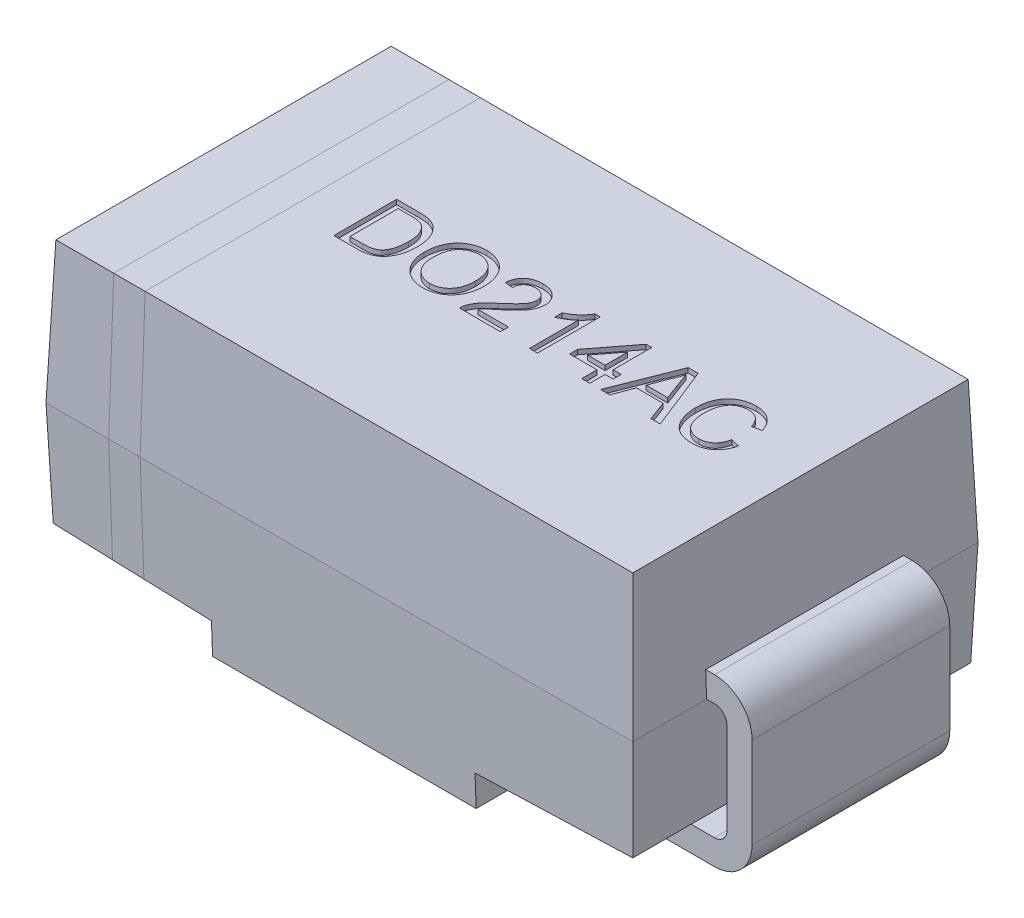
from build123d import *

# Parameters (mm, degrees)
SKETCH1_W                      = 4.7498
SKETCH1_H                      = 2.794
EXTRUDE1_DEPTH                 = 1.143
EXTRUDE1_TAPER                 = 2
EXTRUDE1_OTHER_WAY_DEPTH       = 1.143
EXTRUDE1_OTHER_WAY_TAPER       = 2
CUT_EXTRUDE1_REACH             = 3.397
CUT_EXTRUDE1_DIRECTION_2_REACH = 3.397
EXTRUDE2_DEPTH                 = 0.8001
CUT_EXTRUDE2_DEPTH             = 0.0381


with BuildPart() as part:
    # Sketch1 → Extrude1 (new body)
    with BuildSketch(Plane(origin=(0, 0, 0), x_dir=(1, 0, 0), z_dir=(0, 1, 0))):
        Rectangle(SKETCH1_W, SKETCH1_H)
    extrude(amount=EXTRUDE1_DEPTH, taper=EXTRUDE1_TAPER)

    # Sketch1 → Extrude1 other way (add)
    with BuildSketch(Plane(origin=(0, 0, 0), x_dir=(1, 0, 0), z_dir=(0, 1, 0))):
        Rectangle(SKETCH1_W, SKETCH1_H)
    extrude(amount=-EXTRUDE1_OTHER_WAY_DEPTH, taper=EXTRUDE1_OTHER_WAY_TAPER)

    # Sketch2 → Cut-Extrude1 (cut, up to next)
    with BuildSketch(Plane.XY, mode=Mode.PRIVATE) as cut_extrude1_sk1:
        Polygon((1.0668, -0.889), (1.0668, -1.143), (2.33498556, -1.143), (2.345414656, -0.844349792), align=None)
    cut_extrude1_tool1 = extrude(cut_extrude1_sk1.sketch, amount=CUT_EXTRUDE1_REACH, mode=Mode.PRIVATE) & part.part
    add(cut_extrude1_tool1.solids().sort_by_distance((1.720586, -1.004365, 0))[0], mode=Mode.SUBTRACT)
    # Sketch2 → Cut-Extrude1 (cut, up to next)
    with BuildSketch(Plane.XY, mode=Mode.PRIVATE) as cut_extrude1_sk2:
        Polygon((-1.0668, -0.889), (-1.0668, -1.143), (-2.33498556, -1.143), (-2.345414656, -0.844349792), align=None)
    cut_extrude1_tool2 = extrude(cut_extrude1_sk2.sketch, amount=CUT_EXTRUDE1_REACH, mode=Mode.PRIVATE) & part.part
    add(cut_extrude1_tool2.solids().sort_by_distance((-1.720586, -1.004365, 0))[0], mode=Mode.SUBTRACT)

    # Sketch2 → Cut-Extrude1 direction 2 (cut, up to next)
    with BuildSketch(Plane.XY, mode=Mode.PRIVATE) as cut_extrude1_direction_2_sk1:
        Polygon((1.0668, -0.889), (1.0668, -1.143), (2.33498556, -1.143), (2.345414656, -0.844349792), align=None)
    cut_extrude1_direction_2_tool1 = extrude(cut_extrude1_direction_2_sk1.sketch, amount=-CUT_EXTRUDE1_DIRECTION_2_REACH, mode=Mode.PRIVATE) & part.part
    add(cut_extrude1_direction_2_tool1.solids().sort_by_distance((1.720586, -1.004365, 0))[0], mode=Mode.SUBTRACT)
    # Sketch2 → Cut-Extrude1 direction 2 (cut, up to next)
    with BuildSketch(Plane.XY, mode=Mode.PRIVATE) as cut_extrude1_direction_2_sk2:
        Polygon((-1.0668, -0.889), (-1.0668, -1.143), (-2.33498556, -1.143), (-2.345414656, -0.844349792), align=None)
    cut_extrude1_direction_2_tool2 = extrude(cut_extrude1_direction_2_sk2.sketch, amount=-CUT_EXTRUDE1_DIRECTION_2_REACH, mode=Mode.PRIVATE) & part.part
    add(cut_extrude1_direction_2_tool2.solids().sort_by_distance((-1.720586, -1.004365, 0))[0], mode=Mode.SUBTRACT)

    # Sketch3 → Extrude2 (add, symmetric)
    with BuildSketch(Plane.XY):
        with BuildLine():
            Line((2.3678041, 0.2032), (2.4384, 0.2032))
            ThreePointArc((2.4384, 0.2032), (2.653926147, 0.113926147), (2.7432, -0.1016))
            Line((2.7432, -0.1016), (2.7432, -0.8382))
            ThreePointArc((2.7432, -0.8382), (2.653926147, -1.053726147), (2.4384, -1.143))
            Line((2.4384, -1.143), (1.5367, -1.143))
            Line((1.5367, -1.143), (1.5367, -0.9398))
            Line((1.5367, -0.9398), (2.4384, -0.9398))
            ThreePointArc((2.4384, -0.9398), (2.510242049, -0.910042049), (2.54, -0.8382))
            Line((2.54, -0.8382), (2.54, -0.1016))
            ThreePointArc((2.54, -0.1016), (2.510242049, -0.029757951), (2.4384, 0))
            Line((2.4384, 0), (2.3749, 0))
            Line((2.3749, 0), (2.3678041, 0.2032))
        make_face()
        with BuildLine():
            Line((-2.367463797, 0.212944979), (-2.3749, 0))
            Line((-2.3749, 0), (-2.4384, 0))
            ThreePointArc((-2.4384, 0), (-2.510242049, -0.029757951), (-2.54, -0.1016))
            Line((-2.54, -0.1016), (-2.54, -0.8382))
            ThreePointArc((-2.54, -0.8382), (-2.510242049, -0.910042049), (-2.4384, -0.9398))
            Line((-2.4384, -0.9398), (-1.5367, -0.9398))
            Line((-1.5367, -0.9398), (-1.5367, -1.143))
            Line((-1.5367, -1.143), (-2.4384, -1.143))
            ThreePointArc((-2.4384, -1.143), (-2.653926147, -1.053726147), (-2.7432, -0.8382))
            Line((-2.7432, -0.8382), (-2.7432, -0.1016))
            ThreePointArc((-2.7432, -0.1016), (-2.653926147, 0.113926147), (-2.4384, 0.2032))
            Line((-2.4384, 0.2032), (-2.367463797, 0.212944979))
        make_face()
    extrude(amount=EXTRUDE2_DEPTH, both=True)

    # Sketch5 → Cut-Extrude2 (cut)
    with BuildSketch(Plane(origin=(0, 1.143, 0), x_dir=(1, 0, 0), z_dir=(0, 1, 0))):
        with BuildLine():
            Line((-1.239701999, -0.201883132), (-1.239701999, 0.306116868))
            Line((-1.239701999, 0.306116868), (-1.065992864, 0.306116868))
            add(Edge.make_bspline(
                [(-1.065992864, 0.306116868), (-1.061243888, 0.306095414), (-1.052016264, 0.306053727), (-1.038612202, 0.305788039), (-1.026061099, 0.305147202), (-1.014420787, 0.304366578), (-1.003632561, 0.303327244), (-0.993710201, 0.30216501), (-0.984645968, 0.300649027), (-0.978947184, 0.299388963), (-0.976238057, 0.298789945)],
                knots=[0, 0, 0, 0, 1.4247e-05, 2.7683e-05, 4.0215e-05, 5.1946e-05, 6.2679e-05, 7.2727e-05, 8.1911e-05, 9.0234e-05, 9.0234e-05, 9.0234e-05, 9.0234e-05], degree=3))
            add(Edge.make_bspline(
                [(-0.976238057, 0.298789945), (-0.969231785, 0.296951768), (-0.95546728, 0.293340489), (-0.936037234, 0.285217384), (-0.918199605, 0.275028432), (-0.907620769, 0.266635663), (-0.902358249, 0.262460618)],
                knots=[0, 0, 0, 0, 2.1708e-05, 4.2648e-05, 6.2982e-05, 8.3111e-05, 8.3111e-05, 8.3111e-05, 8.3111e-05], degree=3))
            add(Edge.make_bspline(
                [(-0.902358249, 0.262460618), (-0.89909078, 0.25959125), (-0.892541052, 0.253839526), (-0.88354504, 0.24436314), (-0.875199588, 0.234310235), (-0.86725543, 0.22385388), (-0.860220668, 0.212612863), (-0.853626566, 0.200910731), (-0.847874912, 0.188512489), (-0.842580601, 0.175620761), (-0.837863731, 0.162185298), (-0.833988043, 0.148214777), (-0.83042752, 0.133855083), (-0.827779317, 0.11894925), (-0.825467573, 0.103623709), (-0.824000015, 0.087790743), (-0.823047815, 0.071497617), (-0.822937469, 0.060462837), (-0.822881486, 0.054864464)],
                knots=[0, 0, 0, 0, 1.304e-05, 2.614e-05, 3.9143e-05, 5.223e-05, 6.5498e-05, 7.8891e-05, 9.2502e-05, 0.000106467, 0.000120692, 0.000135188, 0.000149948, 0.000165057, 0.000180585, 0.000196432, 0.00021274, 0.000229534, 0.000229534, 0.000229534, 0.000229534], degree=3))
            add(Edge.make_bspline(
                [(-0.822881486, 0.054864464), (-0.823017946, 0.045495698), (-0.823283494, 0.027264299), (-0.825909664, 0.000747068), (-0.829973439, -0.024178261), (-0.835887689, -0.047362018), (-0.843171704, -0.06867562), (-0.851117933, -0.088293138), (-0.860264607, -0.105876545), (-0.870298303, -0.121574478), (-0.881049143, -0.135486258), (-0.892311923, -0.147820678), (-0.904120032, -0.158583197), (-0.916413485, -0.168056265), (-0.929830751, -0.175900226), (-0.944231069, -0.182943442), (-0.960081634, -0.188602663), (-0.977083949, -0.193552909), (-0.995437713, -0.197261514), (-1.01504354, -0.199986716), (-1.035978483, -0.20163468), (-1.050352268, -0.20179871), (-1.057750076, -0.201883132)],
                knots=[0, 0, 0, 0, 2.8098e-05, 5.4679e-05, 7.9857e-05, 0.000103798, 0.000126356, 0.00014739, 0.000167235, 0.000185725, 0.000203209, 0.000219919, 0.000235766, 0.000251091, 0.000266379, 0.00028231, 0.000299115, 0.000316798, 0.000335399, 0.00035523, 0.000376155, 0.000398345, 0.000398345, 0.000398345, 0.000398345], degree=3))
            Line((-1.057750076, -0.201883132), (-1.239701999, -0.201883132))
        make_face()
        with BuildLine():
            Line((-1.168060973, -0.143267747), (-1.063347031, -0.143267747))
            add(Edge.make_bspline(
                [(-1.063347031, -0.143267747), (-1.055711551, -0.143153447), (-1.041266923, -0.142937217), (-1.020887835, -0.141276575), (-1.003101588, -0.138412191), (-0.987710951, -0.134336945), (-0.974357171, -0.129067027), (-0.962599102, -0.122836724), (-0.952140153, -0.115766731), (-0.946248626, -0.110110441), (-0.943368665, -0.107345472)],
                knots=[0, 0, 0, 0, 2.2905e-05, 4.3331e-05, 6.1282e-05, 7.6883e-05, 9.0999e-05, 0.000104246, 0.000116751, 0.00012871, 0.00012871, 0.00012871, 0.00012871], degree=3))
            add(Edge.make_bspline(
                [(-0.943368665, -0.107345472), (-0.939620972, -0.103060267), (-0.93192192, -0.094256983), (-0.922334603, -0.078878113), (-0.913973997, -0.06157394), (-0.906985005, -0.04216025), (-0.901254212, -0.020702708), (-0.897431992, 0.002990885), (-0.894932992, 0.028759424), (-0.894662746, 0.04668306), (-0.894522512, 0.055983855)],
                knots=[0, 0, 0, 0, 1.7056e-05, 3.5038e-05, 5.4153e-05, 7.4628e-05, 9.6843e-05, 0.000120683, 0.000146545, 0.00017444, 0.00017444, 0.00017444, 0.00017444], degree=3))
            add(Edge.make_bspline(
                [(-0.894522512, 0.055983855), (-0.8946094, 0.062463826), (-0.894778307, 0.075060626), (-0.895831299, 0.093412052), (-0.89791006, 0.11058715), (-0.900568601, 0.126615628), (-0.904198421, 0.141446535), (-0.908349183, 0.155221969), (-0.913570985, 0.16776185), (-0.9195297, 0.179162987), (-0.92606648, 0.189501095), (-0.93287804, 0.19899823), (-0.939999237, 0.207623254), (-0.947580964, 0.215253449), (-0.955395306, 0.222114456), (-0.963587943, 0.228065808), (-0.972135949, 0.233105676), (-0.978142578, 0.23572191), (-0.981122672, 0.237019913)],
                knots=[0, 0, 0, 0, 1.9441e-05, 3.7792e-05, 5.511e-05, 7.1322e-05, 8.6501e-05, 0.000100889, 0.000114439, 0.000127183, 0.000139437, 0.000151101, 0.000162229, 0.00017295, 0.000183337, 0.000193393, 0.000203289, 0.000213033, 0.000213033, 0.000213033, 0.000213033], degree=3))
            add(Edge.make_bspline(
                [(-0.981122672, 0.237019913), (-0.983451199, 0.237872053), (-0.988385196, 0.239677682), (-0.996437956, 0.241721383), (-1.005424918, 0.243602154), (-1.015434664, 0.24492221), (-1.026416568, 0.24620516), (-1.038438894, 0.246984783), (-1.051438591, 0.247338087), (-1.060429648, 0.247445805), (-1.065076999, 0.247501483)],
                knots=[0, 0, 0, 0, 7.434e-06, 1.5753e-05, 2.4893e-05, 3.4967e-05, 4.6025e-05, 5.8061e-05, 7.1093e-05, 8.5036e-05, 8.5036e-05, 8.5036e-05, 8.5036e-05], degree=3))
            Line((-1.065076999, 0.247501483), (-1.168060973, 0.247501483))
            Line((-1.168060973, 0.247501483), (-1.168060973, -0.143267747))
        make_face(mode=Mode.SUBTRACT)
        with BuildLine():
            add(Edge.make_bspline(
                [(-0.757753281, 0.045400522), (-0.75757672, 0.055585484), (-0.757232699, 0.075430366), (-0.754018329, 0.104327072), (-0.748799016, 0.131515092), (-0.741337548, 0.156992308), (-0.731880115, 0.180798644), (-0.720382798, 0.202988005), (-0.706499766, 0.223309223), (-0.69079452, 0.241955744), (-0.673252481, 0.258440635), (-0.654575195, 0.27308158), (-0.634529442, 0.285293859), (-0.613300429, 0.295377175), (-0.590797963, 0.303118853), (-0.567085224, 0.308538733), (-0.542187573, 0.312035082), (-0.525169446, 0.312428607), (-0.516473633, 0.312629689)],
                knots=[0, 0, 0, 0, 3.0546e-05, 5.9517e-05, 8.7098e-05, 0.000113504, 0.000139033, 0.00016384, 0.000188311, 0.000212716, 0.00023683, 0.000260402, 0.000283789, 0.000307095, 0.000330781, 0.000355021, 0.000379977, 0.000406052, 0.000406052, 0.000406052, 0.000406052], degree=3))
            add(Edge.make_bspline(
                [(-0.516473633, 0.312629689), (-0.510738148, 0.312529536), (-0.49934851, 0.312330652), (-0.482509948, 0.310817406), (-0.466104077, 0.308116525), (-0.450147054, 0.304497041), (-0.434595443, 0.299748436), (-0.419439958, 0.294142853), (-0.404813267, 0.287196745), (-0.390618063, 0.279419886), (-0.37702191, 0.270721134), (-0.36424428, 0.261111639), (-0.352315779, 0.250664079), (-0.341076174, 0.239550183), (-0.330900516, 0.227394872), (-0.321368422, 0.214568418), (-0.312753803, 0.200843388), (-0.305026092, 0.186332234), (-0.298116732, 0.171259078), (-0.292211351, 0.155561449), (-0.287140507, 0.139427651), (-0.282895784, 0.122762188), (-0.27985008, 0.105570759), (-0.277424753, 0.087927438), (-0.276148236, 0.069774563), (-0.275920087, 0.057511973), (-0.275804563, 0.051302765)],
                knots=[0, 0, 0, 0, 1.7205e-05, 3.4167e-05, 5.0663e-05, 6.7054e-05, 8.3215e-05, 9.9413e-05, 0.000115483, 0.000131742, 0.000147945, 0.000163861, 0.000179657, 0.000195487, 0.000211227, 0.000227164, 0.000243398, 0.000259788, 0.000276455, 0.000293106, 0.000310067, 0.000327171, 0.000344656, 0.000362416, 0.000380578, 0.000399208, 0.000399208, 0.000399208, 0.000399208], degree=3))
            add(Edge.make_bspline(
                [(-0.275804563, 0.051302765), (-0.275910408, 0.044991168), (-0.276119524, 0.03252152), (-0.277534486, 0.014100034), (-0.280022481, -0.003792609), (-0.283322383, -0.021209763), (-0.287744151, -0.038115167), (-0.292998743, -0.054557291), (-0.299354469, -0.070438203), (-0.306532555, -0.085796178), (-0.314654557, -0.100419991), (-0.323613676, -0.114207386), (-0.333416259, -0.127029392), (-0.343913407, -0.139043303), (-0.355350255, -0.150034288), (-0.367585974, -0.160105119), (-0.380573518, -0.169350778), (-0.394356518, -0.177520861), (-0.40868762, -0.184682231), (-0.423283234, -0.191035657), (-0.438154202, -0.196454111), (-0.453351348, -0.200845229), (-0.468833215, -0.204163474), (-0.484556237, -0.206648211), (-0.500571955, -0.208078932), (-0.511348839, -0.208289736), (-0.516778922, -0.208395953)],
                knots=[0, 0, 0, 0, 1.8935e-05, 3.7409e-05, 5.5384e-05, 7.3107e-05, 9.0557e-05, 0.000107774, 0.000124857, 0.000141837, 0.0001586, 0.000174999, 0.000191119, 0.000206981, 0.000222815, 0.000238646, 0.000254486, 0.000270594, 0.000286659, 0.00030252, 0.000318326, 0.000334107, 0.000349936, 0.000365796, 0.000381837, 0.000398127, 0.000398127, 0.000398127, 0.000398127], degree=3))
            add(Edge.make_bspline(
                [(-0.516778922, -0.208395953), (-0.522617467, -0.208309571), (-0.534182162, -0.208138469), (-0.551275094, -0.206430589), (-0.56794278, -0.203825157), (-0.584136765, -0.200063701), (-0.59983492, -0.195156616), (-0.615055821, -0.189217236), (-0.629852999, -0.182324938), (-0.644042848, -0.174282374), (-0.65757707, -0.165339907), (-0.670324487, -0.15554199), (-0.682278049, -0.144978919), (-0.693245952, -0.1334761), (-0.703583412, -0.121450514), (-0.712877089, -0.108455178), (-0.721430501, -0.094784811), (-0.728990539, -0.080307639), (-0.735819902, -0.065453866), (-0.741573788, -0.050218743), (-0.746630338, -0.034826795), (-0.750657369, -0.019183151), (-0.753866422, -0.003323898), (-0.756024278, 0.012724574), (-0.757582698, 0.028986168), (-0.757696134, 0.039901536), (-0.757753281, 0.045400522)],
                knots=[0, 0, 0, 0, 1.7511e-05, 3.4684e-05, 5.1481e-05, 6.8094e-05, 8.4509e-05, 0.00010078, 0.000117077, 0.000133436, 0.000149665, 0.000165704, 0.000181634, 0.000197467, 0.00021335, 0.000229167, 0.000245347, 0.000261689, 0.000278129, 0.000294363, 0.000310518, 0.00032671, 0.000342795, 0.000359029, 0.000375272, 0.000391762, 0.000391762, 0.000391762, 0.000391762], degree=3))
        make_face()
        with BuildLine():
            add(Edge.make_bspline(
                [(-0.686112255, 0.044586419), (-0.686002469, 0.037252328), (-0.685788393, 0.022951366), (-0.683339249, 0.002101325), (-0.679623064, -0.01757175), (-0.674500696, -0.036123087), (-0.667614978, -0.053369216), (-0.659382211, -0.069475854), (-0.649525196, -0.084335935), (-0.638261407, -0.097907889), (-0.62587253, -0.110099915), (-0.612633758, -0.120749002), (-0.598542115, -0.129666858), (-0.583753832, -0.137030453), (-0.56816269, -0.14277841), (-0.551815387, -0.14681448), (-0.53469991, -0.149338715), (-0.523029266, -0.149631449), (-0.51708421, -0.149780568)],
                knots=[0, 0, 0, 0, 2.1992e-05, 4.2883e-05, 6.2881e-05, 8.2018e-05, 0.000100518, 0.000118496, 0.000136192, 0.000153899, 0.000171313, 0.000188255, 0.00020477, 0.000221245, 0.000237729, 0.000254512, 0.000271681, 0.000289508, 0.000289508, 0.000289508, 0.000289508], degree=3))
            add(Edge.make_bspline(
                [(-0.51708421, -0.149780568), (-0.511038386, -0.149629243), (-0.499200678, -0.149332949), (-0.481827163, -0.14685278), (-0.465320378, -0.142630397), (-0.449516712, -0.13700945), (-0.434701881, -0.129410887), (-0.420529407, -0.120513011), (-0.407385635, -0.109640062), (-0.394947921, -0.097426472), (-0.383792129, -0.083543485), (-0.373893713, -0.068333082), (-0.365852936, -0.051567145), (-0.35891081, -0.033615006), (-0.353827386, -0.014137362), (-0.350070424, 0.006644365), (-0.347806399, 0.028797024), (-0.347567985, 0.044004413), (-0.347445589, 0.05181158)],
                knots=[0, 0, 0, 0, 1.8132e-05, 3.5503e-05, 5.2508e-05, 6.9183e-05, 8.5703e-05, 0.000102359, 0.000119285, 0.000136771, 0.000154571, 0.000172608, 0.000191086, 0.00021025, 0.000230269, 0.000251368, 0.000273563, 0.00029698, 0.00029698, 0.00029698, 0.00029698], degree=3))
            add(Edge.make_bspline(
                [(-0.347445589, 0.05181158), (-0.347488844, 0.056834202), (-0.347573694, 0.06668677), (-0.348697399, 0.081209568), (-0.350146835, 0.095280623), (-0.352353624, 0.10888178), (-0.355394858, 0.121956712), (-0.35876403, 0.13460496), (-0.362977061, 0.146717528), (-0.367757332, 0.158341916), (-0.373106374, 0.169418447), (-0.379139382, 0.179853742), (-0.385786241, 0.18960723), (-0.392867609, 0.198863829), (-0.400775613, 0.207265268), (-0.409129479, 0.21516643), (-0.418118964, 0.222404075), (-0.427654355, 0.228980092), (-0.437600382, 0.234899544), (-0.447936541, 0.239965827), (-0.458498161, 0.24441592), (-0.46946203, 0.247827104), (-0.480676757, 0.250578273), (-0.492187678, 0.252668042), (-0.50403752, 0.253750222), (-0.512028101, 0.253925644), (-0.516066582, 0.254014304)],
                knots=[0, 0, 0, 0, 1.5064e-05, 2.955e-05, 4.3676e-05, 5.7495e-05, 7.0851e-05, 8.3935e-05, 9.6743e-05, 0.000109292, 0.000121625, 0.000133617, 0.000145415, 0.000157017, 0.000168539, 0.000179985, 0.000191492, 0.000203122, 0.00021471, 0.000226179, 0.000237631, 0.000249056, 0.000260582, 0.00027226, 0.000284118, 0.000296234, 0.000296234, 0.000296234, 0.000296234], degree=3))
            add(Edge.make_bspline(
                [(-0.516066582, 0.254014304), (-0.521774425, 0.253900948), (-0.533036635, 0.253677285), (-0.549615948, 0.251190923), (-0.565600204, 0.247475959), (-0.581014207, 0.242282241), (-0.595726126, 0.235404941), (-0.60981218, 0.226970875), (-0.623397404, 0.217209688), (-0.636267579, 0.205883551), (-0.648265397, 0.192872584), (-0.658408349, 0.177533053), (-0.666957105, 0.160231145), (-0.67409516, 0.141010715), (-0.679537716, 0.119722914), (-0.683299203, 0.096459355), (-0.685674129, 0.071195522), (-0.68596248, 0.053682874), (-0.686112255, 0.044586419)],
                knots=[0, 0, 0, 0, 1.7111e-05, 3.3762e-05, 5.0176e-05, 6.6299e-05, 8.2461e-05, 9.8797e-05, 0.000115489, 0.000132577, 0.000150155, 0.000168416, 0.00018753, 0.000207945, 0.000229813, 0.000253335, 0.000278579, 0.000305864, 0.000305864, 0.000305864, 0.000305864], degree=3))
        make_face(mode=Mode.SUBTRACT)
        with BuildLine():
            Line((0.108451847, -0.136754927), (0.108451847, -0.201883132))
            Line((0.108451847, -0.201883132), (-0.223701999, -0.201883132))
            add(Edge.make_bspline(
                [(-0.223701999, -0.201883132), (-0.223708799, -0.19801238), (-0.223722376, -0.190283849), (-0.222414584, -0.178853842), (-0.22036632, -0.167575464), (-0.218050349, -0.160343089), (-0.21688389, -0.15670044)],
                knots=[0, 0, 0, 0, 1.1603e-05, 2.3167e-05, 3.4463e-05, 4.5925e-05, 4.5925e-05, 4.5925e-05, 4.5925e-05], degree=3))
            add(Edge.make_bspline(
                [(-0.21688389, -0.15670044), (-0.214728661, -0.150748786), (-0.210340261, -0.138630238), (-0.201449316, -0.121144867), (-0.190991464, -0.103765243), (-0.180809273, -0.089615776), (-0.171484585, -0.07831134), (-0.163664619, -0.069466928), (-0.154998662, -0.06041363), (-0.145493656, -0.051153099), (-0.13524108, -0.04162536), (-0.124226944, -0.031798637), (-0.112321189, -0.021856062), (-0.104009726, -0.01526571), (-0.099754883, -0.011891946)],
                knots=[0, 0, 0, 0, 1.8974e-05, 3.8634e-05, 5.8722e-05, 7.9791e-05, 9.0853e-05, 0.000102676, 0.0001152, 0.000128441, 0.000142481, 0.000157186, 0.000172717, 0.000189007, 0.000189007, 0.000189007, 0.000189007], degree=3))
            add(Edge.make_bspline(
                [(-0.099754883, -0.011891946), (-0.093218394, -0.006390289), (-0.080631968, 0.004203501), (-0.062857963, 0.019923704), (-0.046624302, 0.034520803), (-0.032189488, 0.048250642), (-0.01943546, 0.06098005), (-0.008332271, 0.072680187), (0.001215614, 0.083314539), (0.009091635, 0.093268026), (0.015736875, 0.102666886), (0.02136813, 0.111834894), (0.026061033, 0.120932194), (0.029969593, 0.12993), (0.033060933, 0.138866791), (0.03516812, 0.147768604), (0.036597142, 0.156547111), (0.036740117, 0.162388427), (0.036810822, 0.165277124)],
                knots=[0, 0, 0, 0, 2.563e-05, 4.9352e-05, 7.1182e-05, 9.112e-05, 0.00010911, 0.000125234, 0.000139507, 0.000151967, 0.000163289, 0.000174022, 0.000184217, 0.000193972, 0.000203433, 0.00021254, 0.000221391, 0.000230051, 0.000230051, 0.000230051, 0.000230051], degree=3))
            add(Edge.make_bspline(
                [(0.036810822, 0.165277124), (0.036740108, 0.168132117), (0.036601372, 0.173733459), (0.035285049, 0.181930986), (0.033452622, 0.189825402), (0.030490145, 0.197274587), (0.026963906, 0.204499143), (0.022440653, 0.211270782), (0.017208179, 0.21775827), (0.01121744, 0.223790564), (0.004674149, 0.229449818), (-0.002637045, 0.234154034), (-0.010235947, 0.238389229), (-0.018384711, 0.241794569), (-0.027070097, 0.244295171), (-0.036228878, 0.246109964), (-0.045859602, 0.24726064), (-0.052431894, 0.247419985), (-0.055793345, 0.247501483)],
                knots=[0, 0, 0, 0, 8.558e-06, 1.679e-05, 2.4861e-05, 3.2817e-05, 4.0781e-05, 4.8938e-05, 5.7187e-05, 6.575e-05, 7.4415e-05, 8.3079e-05, 9.1778e-05, 0.00010049, 0.000109506, 0.000118846, 0.000128477, 0.00013856, 0.00013856, 0.00013856, 0.00013856], degree=3))
            add(Edge.make_bspline(
                [(-0.055793345, 0.247501483), (-0.059324456, 0.247420389), (-0.066235101, 0.24726168), (-0.076336612, 0.246106415), (-0.085926246, 0.244341326), (-0.094981114, 0.241642656), (-0.103490194, 0.238242995), (-0.111418832, 0.233963727), (-0.118893997, 0.229133207), (-0.125680269, 0.223414235), (-0.131817005, 0.217073063), (-0.137264998, 0.210169444), (-0.14172881, 0.202570154), (-0.14541521, 0.194442283), (-0.148379384, 0.185760281), (-0.150531273, 0.176457775), (-0.151704498, 0.166561626), (-0.151940423, 0.159784746), (-0.152060973, 0.156321996)],
                knots=[0, 0, 0, 0, 1.0591e-05, 2.0728e-05, 3.0467e-05, 3.9805e-05, 4.9027e-05, 5.7904e-05, 6.6795e-05, 7.5681e-05, 8.4461e-05, 9.3234e-05, 0.000101995, 0.00011083, 0.000119969, 0.000129473, 0.000139419, 0.000149812, 0.000149812, 0.000149812, 0.000149812], degree=3))
            Line((-0.152060973, 0.156321996), (-0.217189178, 0.162834817))
            add(Edge.make_bspline(
                [(-0.217189178, 0.162834817), (-0.216522824, 0.168510899), (-0.21522649, 0.179553228), (-0.211997497, 0.195546182), (-0.207464284, 0.210424214), (-0.202039913, 0.224394754), (-0.195239951, 0.237219983), (-0.18755318, 0.249165174), (-0.178486989, 0.259851478), (-0.168471252, 0.269615741), (-0.157396238, 0.278220626), (-0.145365978, 0.285738187), (-0.132385975, 0.292026164), (-0.118528524, 0.297232346), (-0.103761811, 0.301182407), (-0.088106727, 0.304014974), (-0.071538095, 0.305761), (-0.060173468, 0.305996553), (-0.054368665, 0.306116868)],
                knots=[0, 0, 0, 0, 1.7141e-05, 3.3347e-05, 4.8864e-05, 6.3755e-05, 7.823e-05, 9.2342e-05, 0.000106284, 0.000120173, 0.000134239, 0.000148273, 0.000162654, 0.000177435, 0.000192617, 0.000208445, 0.000225123, 0.000242535, 0.000242535, 0.000242535, 0.000242535], degree=3))
            add(Edge.make_bspline(
                [(-0.054368665, 0.306116868), (-0.048494382, 0.306016278), (-0.037051244, 0.305820327), (-0.020376753, 0.303815357), (-0.004643909, 0.300692635), (0.010204963, 0.296340516), (0.024082133, 0.290633591), (0.036998278, 0.283661017), (0.04901295, 0.27549081), (0.059925409, 0.266024892), (0.069765459, 0.255691256), (0.078388811, 0.244663039), (0.085598349, 0.232987353), (0.091736823, 0.220823347), (0.096289955, 0.207914002), (0.099491802, 0.194434824), (0.10166755, 0.180374295), (0.101847331, 0.170780763), (0.101939027, 0.165887701)],
                knots=[0, 0, 0, 0, 1.7616e-05, 3.4315e-05, 5.0301e-05, 6.5692e-05, 8.0659e-05, 9.5229e-05, 0.000109653, 0.000124156, 0.00013848, 0.000152403, 0.00016607, 0.000179587, 0.000193202, 0.000207024, 0.000221113, 0.00023578, 0.00023578, 0.00023578, 0.00023578], degree=3))
            add(Edge.make_bspline(
                [(0.101939027, 0.165887701), (0.10179901, 0.160860635), (0.101518666, 0.150795408), (0.099330547, 0.135750862), (0.09558665, 0.120869583), (0.090623243, 0.105970457), (0.083842195, 0.090994349), (0.075275493, 0.075734664), (0.064647563, 0.060135034), (0.054426474, 0.046873616), (0.044912299, 0.035757203), (0.036478882, 0.026607746), (0.026721906, 0.016887059), (0.016007393, 0.006258494), (0.003898353, -0.004900721), (-0.009257293, -0.016924754), (-0.023747529, -0.029497178), (-0.033806577, -0.038086055), (-0.03900248, -0.042522555)],
                knots=[0, 0, 0, 0, 1.5078e-05, 3.0189e-05, 4.5491e-05, 6.1066e-05, 7.7237e-05, 9.4732e-05, 0.000113501, 0.000133815, 0.00014493, 0.000157388, 0.000171133, 0.000186244, 0.000202661, 0.000220527, 0.000239711, 0.000260208, 0.000260208, 0.000260208, 0.000260208], degree=3))
            add(Edge.make_bspline(
                [(-0.03900248, -0.042522555), (-0.043451985, -0.046144927), (-0.051936508, -0.053052233), (-0.064007386, -0.06306594), (-0.07481922, -0.072248237), (-0.084624845, -0.080299617), (-0.093067146, -0.087609513), (-0.100443491, -0.093857785), (-0.106485894, -0.099358594), (-0.115687403, -0.107714433), (-0.127341899, -0.119624836), (-0.135929431, -0.131197843), (-0.14005296, -0.136754927)],
                knots=[0, 0, 0, 0, 1.7213e-05, 3.2822e-05, 4.705e-05, 5.9767e-05, 7.0882e-05, 8.0551e-05, 8.8765e-05, 9.5392e-05, 0.000117846, 0.000138589, 0.000138589, 0.000138589, 0.000138589], degree=3))
            Line((-0.14005296, -0.136754927), (0.108451847, -0.136754927))
        make_face()
        with BuildLine():
            Line((0.408041591, -0.201883132), (0.342913386, -0.201883132))
            Line((0.342913386, -0.201883132), (0.342913386, 0.19397424))
            add(Edge.make_bspline(
                [(0.342913386, 0.19397424), (0.339163298, 0.190357741), (0.331369151, 0.182841246), (0.31819397, 0.172203528), (0.303488784, 0.16142175), (0.287444549, 0.151053865), (0.271090166, 0.141293619), (0.25528576, 0.132515779), (0.240295193, 0.125087596), (0.230420826, 0.121025837), (0.225682617, 0.119076804)],
                knots=[0, 0, 0, 0, 1.5623e-05, 3.247e-05, 5.0748e-05, 7.0308e-05, 8.975e-05, 0.000107878, 0.000124535, 0.000139901, 0.000139901, 0.000139901, 0.000139901], degree=3))
            Line((0.225682617, 0.119076804), (0.225682617, 0.179116868))
            add(Edge.make_bspline(
                [(0.225682617, 0.179116868), (0.23382098, 0.183308142), (0.249861213, 0.191568894), (0.272522594, 0.205836348), (0.29367943, 0.221302856), (0.312981493, 0.237964993), (0.330284562, 0.254996688), (0.34486611, 0.272182337), (0.357067022, 0.288891989), (0.36318845, 0.300545118), (0.366115309, 0.306116868)],
                knots=[0, 0, 0, 0, 2.7452e-05, 5.4106e-05, 8.024e-05, 0.000106002, 0.00013054, 0.000152991, 0.000173575, 0.000192433, 0.000192433, 0.000192433, 0.000192433], degree=3))
            Line((0.366115309, 0.306116868), (0.408041591, 0.306116868))
            Line((0.408041591, 0.306116868), (0.408041591, -0.201883132))
        make_face()
        Polygon((0.766246719, -0.201883132), (0.766246719, -0.078139542), (0.544810822, -0.078139542), (0.544810822, -0.013011337), (0.785785181, 0.299604047), (0.831374924, 0.299604047), (0.831374924, -0.013011337), (0.896503129, -0.013011337), (0.896503129, -0.078139542), (0.831374924, -0.078139542), (0.831374924, -0.201883132), align=None)
        Polygon((0.766246719, -0.013011337), (0.766246719, 0.169958214), (0.62520345, -0.013011337), align=None, mode=Mode.SUBTRACT)
        Polygon((0.91817861, -0.201883132), (1.11987252, 0.306116868), (1.2006722, 0.306116868), (1.40236611, -0.201883132), (1.326349283, -0.201883132), (1.268548001, -0.04557544), (1.051996719, -0.04557544), (0.994195437, -0.201883132), align=None)
        with BuildLine():
            Line((1.073570437, 0.013039945), (1.246974283, 0.013039945))
            Line((1.246974283, 0.013039945), (1.197619315, 0.146552765))
            add(Edge.make_bspline(
                [(1.197619315, 0.146552765), (1.195727222, 0.151711519), (1.192027822, 0.161797856), (1.186510903, 0.176452452), (1.181470735, 0.190369058), (1.176528435, 0.20334813), (1.172066934, 0.215578201), (1.167954653, 0.226976664), (1.163887642, 0.237464293), (1.161446972, 0.244240381), (1.16027236, 0.247501483)],
                knots=[0, 0, 0, 0, 1.6484e-05, 3.223e-05, 4.6975e-05, 6.0887e-05, 7.3893e-05, 8.603e-05, 9.7238e-05, 0.000107636, 0.000107636, 0.000107636, 0.000107636], degree=3))
            add(Edge.make_bspline(
                [(1.16027236, 0.247501483), (1.158329325, 0.239459893), (1.154435244, 0.223343555), (1.146281986, 0.199730958), (1.136954941, 0.176334308), (1.12938027, 0.161257667), (1.125571238, 0.153676163)],
                knots=[0, 0, 0, 0, 2.4805e-05, 4.9713e-05, 7.4865e-05, 0.000100307, 0.000100307, 0.000100307, 0.000100307], degree=3))
            Line((1.125571238, 0.153676163), (1.073570437, 0.013039945))
        make_face(mode=Mode.SUBTRACT)
        with BuildLine():
            Line((1.801785181, -0.022577042), (1.873426206, -0.039266145))
            add(Edge.make_bspline(
                [(1.873426206, -0.039266145), (1.871631399, -0.045980859), (1.868120532, -0.059115674), (1.861179122, -0.077913047), (1.853388241, -0.095553581), (1.844558847, -0.111990805), (1.834594302, -0.127130218), (1.823758627, -0.141166388), (1.811622636, -0.153804965), (1.798631612, -0.165337641), (1.784684408, -0.17550943), (1.769949178, -0.184292956), (1.754497149, -0.191765954), (1.738265868, -0.197911288), (1.721244814, -0.202536179), (1.703521627, -0.205907071), (1.685044629, -0.207983344), (1.672450073, -0.208256691), (1.666033578, -0.208395953)],
                knots=[0, 0, 0, 0, 2.0842e-05, 4.0769e-05, 6.0039e-05, 7.8661e-05, 9.6669e-05, 0.000114359, 0.000131778, 0.000149153, 0.000166413, 0.000183482, 0.000200549, 0.000217843, 0.000235471, 0.000253393, 0.000271924, 0.00029117, 0.00029117, 0.00029117, 0.00029117], degree=3))
            add(Edge.make_bspline(
                [(1.666033578, -0.208395953), (1.65945013, -0.208300307), (1.64657014, -0.208113184), (1.627701697, -0.206591174), (1.609755956, -0.203951485), (1.592766428, -0.200284015), (1.57667593, -0.195749415), (1.561551184, -0.190044488), (1.547418682, -0.183210396), (1.53416054, -0.175438266), (1.52183307, -0.166608777), (1.510155941, -0.156960212), (1.499412634, -0.146226958), (1.489334527, -0.134662435), (1.480141125, -0.122114092), (1.471494199, -0.108752404), (1.463815802, -0.094341938), (1.456821377, -0.079149864), (1.450682222, -0.06332327), (1.445251216, -0.047174773), (1.440811073, -0.030672197), (1.436988395, -0.013954408), (1.434211406, 0.003119264), (1.432006562, 0.020420712), (1.430794294, 0.038056011), (1.430634772, 0.04991033), (1.430554411, 0.055882092)],
                knots=[0, 0, 0, 0, 1.9749e-05, 3.8636e-05, 5.6741e-05, 7.4126e-05, 9.0746e-05, 0.000106849, 0.000122551, 0.000137788, 0.000152894, 0.000167995, 0.000183178, 0.0001984, 0.00021397, 0.000229806, 0.000246106, 0.000262908, 0.000279954, 0.000297009, 0.000313994, 0.000331202, 0.000348433, 0.000365864, 0.000383512, 0.000401426, 0.000401426, 0.000401426, 0.000401426], degree=3))
            add(Edge.make_bspline(
                [(1.430554411, 0.055882092), (1.430669345, 0.062328851), (1.430896424, 0.075066017), (1.432178281, 0.093860076), (1.434532587, 0.111998642), (1.437802035, 0.129493646), (1.441939194, 0.146359257), (1.447046052, 0.162603692), (1.45305801, 0.178206165), (1.459956737, 0.193183882), (1.467788068, 0.207369653), (1.47631827, 0.220783642), (1.485750821, 0.233205599), (1.495806059, 0.244872848), (1.506735122, 0.255591117), (1.518504636, 0.265384685), (1.531013059, 0.274342882), (1.544258565, 0.282382543), (1.558068021, 0.289436925), (1.572236311, 0.295720325), (1.586819788, 0.300870425), (1.601702832, 0.305152526), (1.616917482, 0.308561477), (1.632499291, 0.310841052), (1.648433861, 0.3123266), (1.659178192, 0.312527928), (1.664608899, 0.312629689)],
                knots=[0, 0, 0, 0, 1.9342e-05, 3.8214e-05, 5.6479e-05, 7.4182e-05, 9.1582e-05, 0.000108544, 0.000125231, 0.000141713, 0.000157973, 0.000173809, 0.000189358, 0.000204723, 0.000219979, 0.000235223, 0.000250613, 0.000266094, 0.000281659, 0.000297106, 0.000312556, 0.000328016, 0.000343546, 0.000359291, 0.00037523, 0.00039152, 0.00039152, 0.00039152, 0.00039152], degree=3))
            add(Edge.make_bspline(
                [(1.664608899, 0.312629689), (1.670685128, 0.312515155), (1.682628557, 0.312290027), (1.700153413, 0.310438307), (1.716937648, 0.307336878), (1.733053993, 0.303268098), (1.748334889, 0.29769709), (1.762946237, 0.291073802), (1.776742682, 0.283116724), (1.789831573, 0.274044531), (1.801999842, 0.263840491), (1.813417771, 0.252748377), (1.823619798, 0.240490965), (1.833009985, 0.227364908), (1.841292885, 0.213188192), (1.848773217, 0.198084422), (1.855206085, 0.18194132), (1.85864799, 0.170697203), (1.860400565, 0.164971836)],
                knots=[0, 0, 0, 0, 1.8226e-05, 3.5825e-05, 5.2791e-05, 6.9402e-05, 8.5625e-05, 0.000101517, 0.000117472, 0.000133337, 0.000149232, 0.000165064, 0.000181025, 0.000197007, 0.00021343, 0.000230223, 0.000247533, 0.00026549, 0.00026549, 0.00026549, 0.00026549], degree=3))
            Line((1.860400565, 0.164971836), (1.78875954, 0.14960565))
            add(Edge.make_bspline(
                [(1.78875954, 0.14960565), (1.787352622, 0.153999575), (1.784598848, 0.162599846), (1.779709253, 0.174856761), (1.774428654, 0.186235182), (1.768631263, 0.196657765), (1.762304514, 0.206127005), (1.755594096, 0.214757988), (1.748339235, 0.222389615), (1.740687501, 0.229197852), (1.732441302, 0.234997818), (1.723793966, 0.240137542), (1.714563165, 0.24438988), (1.704881688, 0.24798648), (1.694659046, 0.25072388), (1.683936866, 0.252649749), (1.672705727, 0.253764347), (1.665052337, 0.253929879), (1.661148963, 0.254014304)],
                knots=[0, 0, 0, 0, 1.3837e-05, 2.7084e-05, 3.9558e-05, 5.1449e-05, 6.2823e-05, 7.3694e-05, 8.4204e-05, 9.437e-05, 0.000104366, 0.000114402, 0.000124508, 0.000134811, 0.000145352, 0.00015621, 0.00016746, 0.00017917, 0.00017917, 0.00017917, 0.00017917], degree=3))
            add(Edge.make_bspline(
                [(1.661148963, 0.254014304), (1.656667532, 0.253949283), (1.647853881, 0.253821405), (1.634905567, 0.252421802), (1.622470681, 0.250360323), (1.610641902, 0.247268959), (1.5993545, 0.243414831), (1.588675458, 0.238615759), (1.578513934, 0.232990685), (1.568983336, 0.226505828), (1.560163761, 0.2192156), (1.55181587, 0.21150869), (1.544340455, 0.203025662), (1.537452457, 0.194046238), (1.531352452, 0.184411743), (1.525861426, 0.174253411), (1.52101438, 0.163487988), (1.515730771, 0.148336469), (1.510343423, 0.128821663), (1.505669892, 0.104941866), (1.502692963, 0.080685845), (1.50236163, 0.064370802), (1.502195437, 0.056187381)],
                knots=[0, 0, 0, 0, 1.3439e-05, 2.643e-05, 3.9028e-05, 5.1221e-05, 6.3064e-05, 7.4771e-05, 8.6295e-05, 9.7868e-05, 0.000109295, 0.000120598, 0.000131914, 0.000143169, 0.000154517, 0.000166083, 0.000177789, 0.000189892, 0.000214187, 0.000238455, 0.000262841, 0.000287383, 0.000287383, 0.000287383, 0.000287383], degree=3))
            add(Edge.make_bspline(
                [(1.502195437, 0.056187381), (1.502382879, 0.045898098), (1.502746533, 0.025935956), (1.506334903, -0.002992483), (1.511805866, -0.029974931), (1.51840853, -0.051026617), (1.525031665, -0.066554736), (1.530388124, -0.077429302), (1.536502309, -0.087492098), (1.543222136, -0.096800272), (1.550634166, -0.105326671), (1.558635132, -0.11311659), (1.567226822, -0.120244984), (1.576511041, -0.126378162), (1.586130426, -0.131823889), (1.595963589, -0.136666333), (1.60601672, -0.140761858), (1.61633038, -0.143943345), (1.626759738, -0.146692592), (1.637419662, -0.14848853), (1.648307113, -0.1495021), (1.655617767, -0.149687001), (1.659317232, -0.149780568)],
                knots=[0, 0, 0, 0, 3.0854e-05, 5.986e-05, 8.7303e-05, 0.000113371, 0.000125864, 0.000137924, 0.000149705, 0.000161144, 0.000172326, 0.000183552, 0.000194614, 0.000205763, 0.000216883, 0.00022776, 0.000238626, 0.000249407, 0.000260119, 0.00027096, 0.000281795, 0.000292894, 0.000292894, 0.000292894, 0.000292894], degree=3))
            add(Edge.make_bspline(
                [(1.659317232, -0.149780568), (1.663732037, -0.14968798), (1.672452839, -0.149505087), (1.685238641, -0.147904209), (1.697563978, -0.145545107), (1.709279531, -0.141904773), (1.720542886, -0.137447612), (1.731261759, -0.131951152), (1.741402442, -0.125340515), (1.751084211, -0.117834758), (1.760128526, -0.109294488), (1.768417155, -0.099788512), (1.775852991, -0.089273492), (1.782747882, -0.077918179), (1.788540858, -0.065383348), (1.793906522, -0.052042606), (1.79837758, -0.037676688), (1.800632997, -0.02768256), (1.801785181, -0.022577042)],
                knots=[0, 0, 0, 0, 1.3239e-05, 2.6152e-05, 3.8605e-05, 5.0838e-05, 6.2894e-05, 7.4909e-05, 8.6906e-05, 9.916e-05, 0.000111614, 0.000124164, 0.000136928, 0.000150209, 0.000163956, 0.000178299, 0.00019333, 0.000209028, 0.000209028, 0.000209028, 0.000209028], degree=3))
        make_face()
    extrude(amount=-CUT_EXTRUDE2_DEPTH, mode=Mode.SUBTRACT)


solid = part.part
